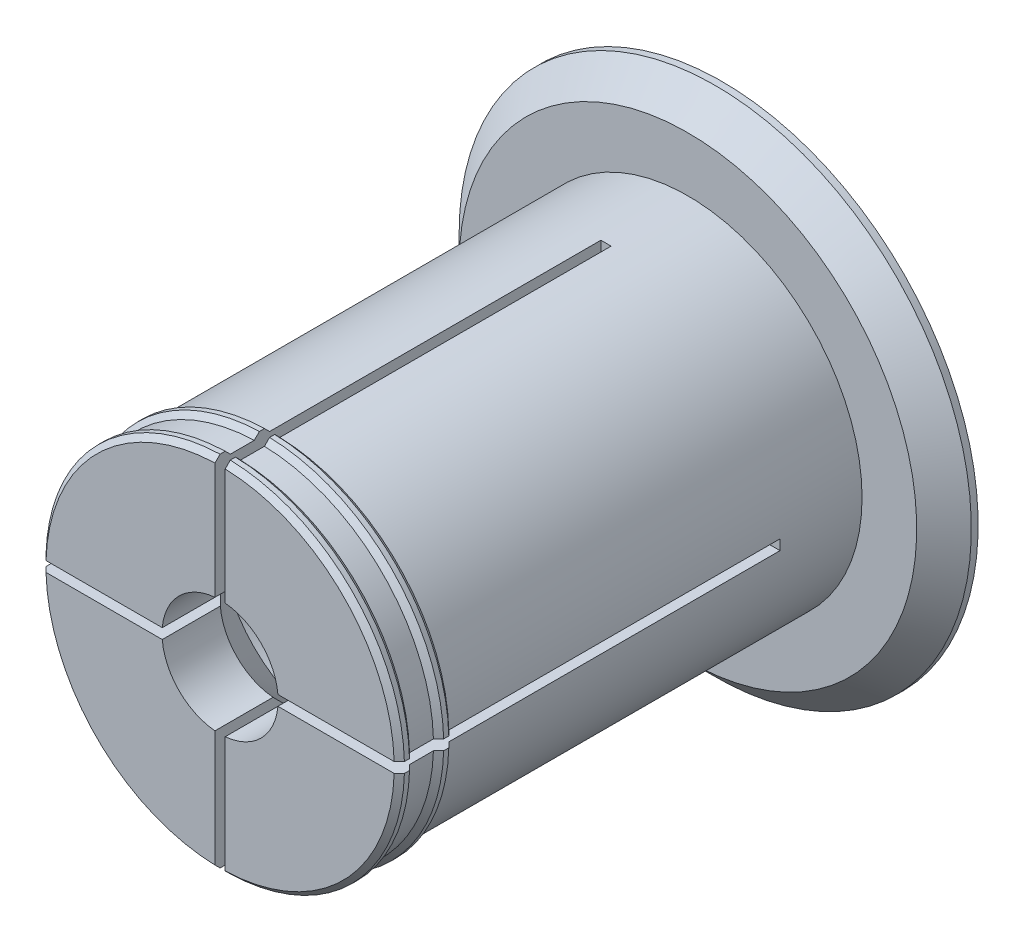
from build123d import *

# Parameters (mm, degrees)
AXLE_BASE_SKETCH_R        = 25.5
AXLE_DEPTH                = 68.5
GUARD_BASE_R              = 37.5
GUARD_DEPTH               = 5
INNER_AXLE_HOLE_BASE_R    = 8.5
INNER_AXLE_HOLE_DEPTH     = 74.5
BEND_START                = -56.5
BEND_ROOM_BASE_W          = 1.5
BEND_ROOM_BASE_H          = 75
BEND_ROOM_1_DEPTH         = 56.500001
BEND_ROOM_2_COUNT         = 2
BEND_ROOM_2_ANGLE         = 90
EASY_REMOVAL_CHAMFER_SIZE = 4


with BuildPart() as part:
    # Axle base sketch → Axle (new body)
    with BuildSketch(Plane.XY):
        Circle(AXLE_BASE_SKETCH_R)
    extrude(amount=AXLE_DEPTH)

    # Guard base → Guard (add)
    with BuildSketch(Plane(origin=(0, 0, 0), x_dir=(-1, 0, 0), z_dir=(0, 0, -1))):
        Circle(GUARD_BASE_R)
    extrude(amount=GUARD_DEPTH)

    # Inner axle hole base → Inner axle hole (cut, through all)
    with BuildSketch(Plane.XY.offset(68.5)):
        Circle(INNER_AXLE_HOLE_BASE_R)
    extrude(amount=-INNER_AXLE_HOLE_DEPTH, mode=Mode.SUBTRACT)

    # Mate ring base → Mate rings (revolve)
    with BuildSketch(Plane(origin=(0, 0, 0), x_dir=(1, 0, 0), z_dir=(0, 1, 0))):
        Polygon((25.5, -68.5), (26.25, -67.75), (26.25, -67), (25.5, -66.25), align=None)
        Polygon((25.5, -62.75), (26.25, -62), (26.25, -61.25), (25.5, -60.5), align=None)
    revolve(axis=Axis((0, 0, 0), (0, 0, -1)))

    # Inner mass remove base → Inner mass remove (revolve, cut)
    with BuildSketch(Plane(origin=(0, 0, 0), x_dir=(0, 0, -1), z_dir=(1, 0, 0))):
        Polygon((-68.5, 0), (-51.5, -17), (-12, -17), (5, 0), align=None)
    revolve(axis=Axis((0, 0, 0), (0, 0, -1)), mode=Mode.SUBTRACT)

    # Bend room base → Bend room 1 (cut)
    with BuildSketch(Plane.XY.offset(68.5).offset(BEND_START)):
        Rectangle(BEND_ROOM_BASE_W, BEND_ROOM_BASE_H)
    bend_room_1 = extrude(amount=BEND_ROOM_1_DEPTH, mode=Mode.SUBTRACT)

    # Bend room 2: Bend room 1 ×2 about axis
    bend_room_2_axis = Axis((0, 0, 0), (0, 0, -1))
    for i in range(1, BEND_ROOM_2_COUNT):
        add(bend_room_1.rotate(bend_room_2_axis, i * BEND_ROOM_2_ANGLE / (BEND_ROOM_2_COUNT - 1)), mode=Mode.SUBTRACT)

    # Easy removal chamfer
    easy_removal_chamfer_edges = [part.edges().sort_by_distance(p)[0] for p in [
        (37.5, 0, 0),
    ]]
    chamfer(easy_removal_chamfer_edges, length=EASY_REMOVAL_CHAMFER_SIZE)


solid = part.part
